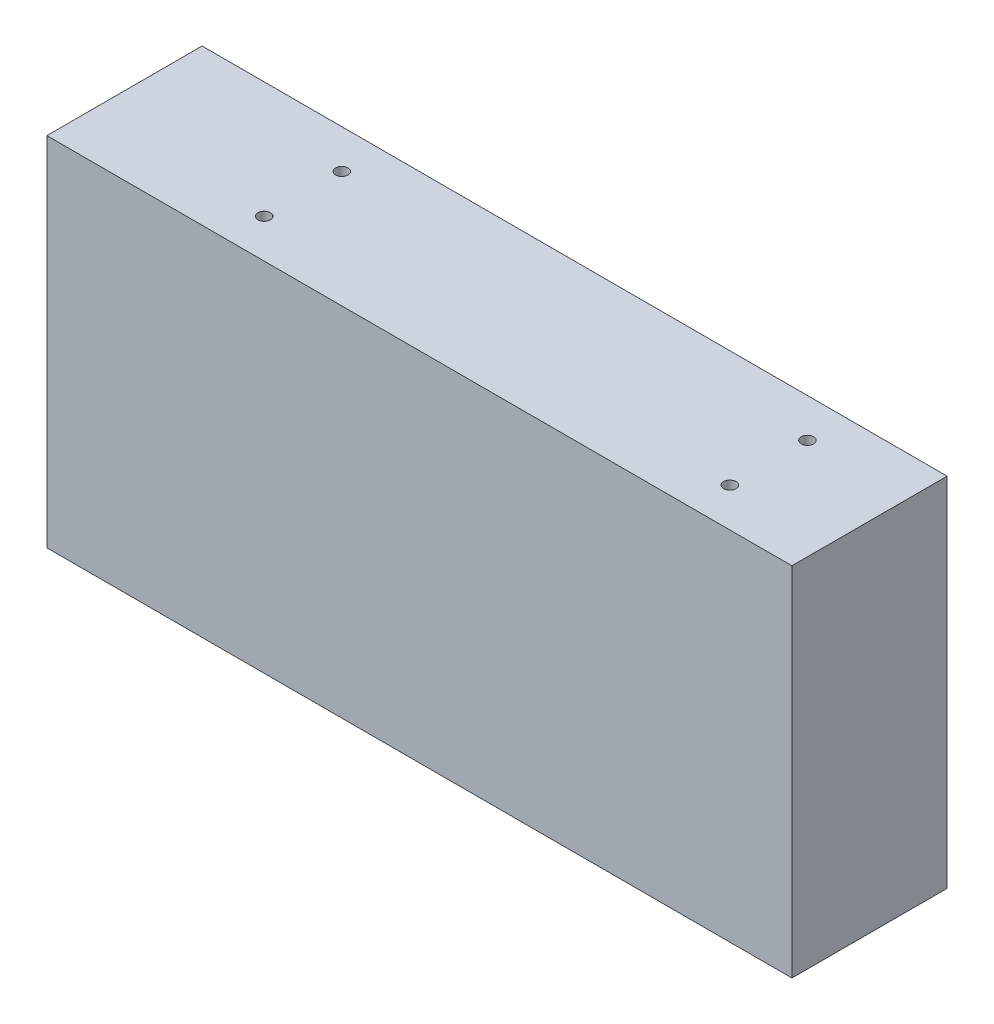
from build123d import *

# Parameters (mm, degrees)
SKETCH_1_W          = 240
SKETCH_1_H          = 115
EXTRUDE_1_DEPTH     = 50
SKETCH_2_R          = 2
CUT_EXTRUDE_1_DEPTH = 5
SKETCH_3_R          = 2
CUT_EXTRUDE_2_DEPTH = 6


with BuildPart() as part:
    # 草图1 → 凸台-拉伸1 (new body)
    with BuildSketch(Plane.XY):
        with Locations((2.942779292, 4.298365123)):
            Rectangle(SKETCH_1_W, SKETCH_1_H)
    extrude(amount=EXTRUDE_1_DEPTH)

    # 草图2 → 切除-拉伸1 (cut)
    with BuildSketch(Plane(origin=(0, 0, 0), x_dir=(-1, 0, 0), z_dir=(0, 0, -1))):
        with Locations((-90.442779292, 29.298365123)):
            Circle(SKETCH_2_R)
        with Locations((59.557220708, 29.298365123)):
            Circle(SKETCH_2_R)
        with Locations((59.557220708, -20.701634877)):
            Circle(SKETCH_2_R)
        with Locations((-90.442779292, -20.701634877)):
            Circle(SKETCH_2_R)
    extrude(amount=-CUT_EXTRUDE_1_DEPTH, mode=Mode.SUBTRACT)

    # 草图3 → 切除-拉伸2 (cut)
    with BuildSketch(Plane(origin=(0, 61.798365123, 0), x_dir=(1, 0, 0), z_dir=(0, 1, 0))):
        with Locations((90.442779292, -37.5)):
            Circle(SKETCH_3_R)
        with Locations((-59.557220708, -37.5)):
            Circle(SKETCH_3_R)
        with Locations((-59.557220708, -12.5)):
            Circle(SKETCH_3_R)
        with Locations((90.442779292, -12.5)):
            Circle(SKETCH_3_R)
    extrude(amount=-CUT_EXTRUDE_2_DEPTH, mode=Mode.SUBTRACT)


solid = part.part
